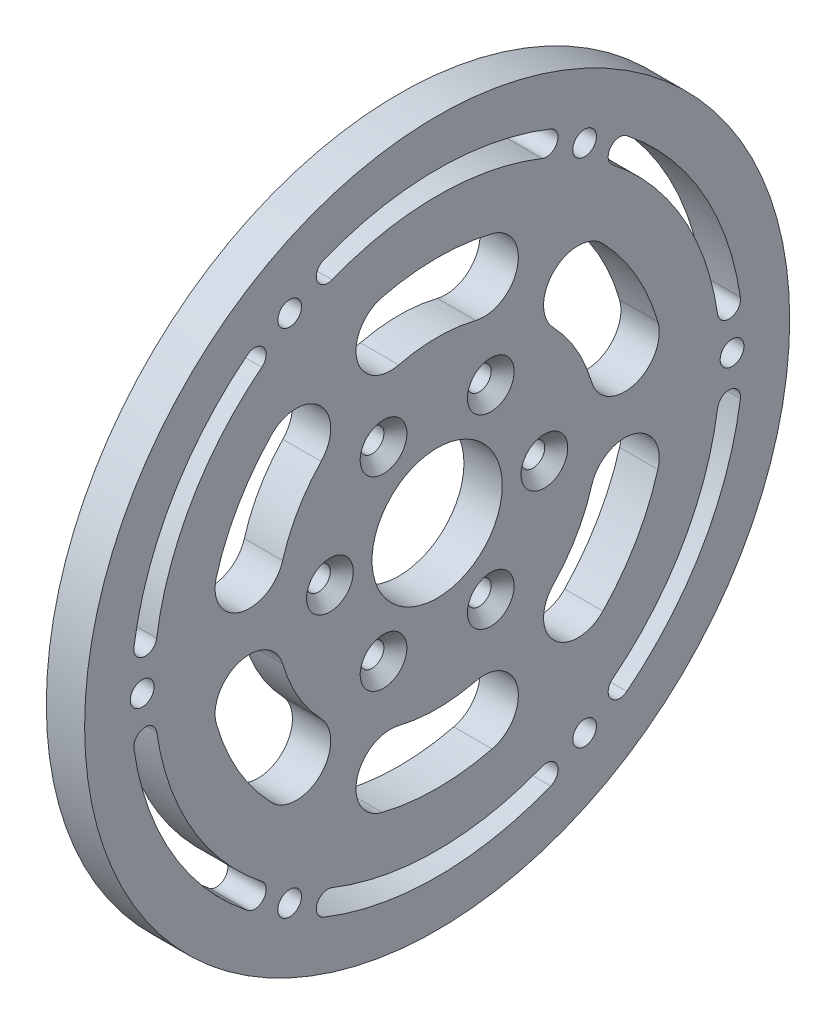
from build123d import *

# Parameters (mm, degrees)
SKETCH_1_W                  = 5
SKETCH_1_H                  = 46.025
CUT_EXTRUDE_1_DEPTH         = 6
CUT_EXTRUDE_2_DEPTH         = 6
CUT_EXTRUDE_3_DEPTH         = 6
CUT_EXTRUDE_4_DEPTH         = 6
CUT_EXTRUDE_5_DEPTH         = 6
CUT_EXTRUDE_6_DEPTH         = 6
CUT_EXTRUDE_7_DEPTH         = 6
CUT_EXTRUDE_8_DEPTH         = 6
CUT_EXTRUDE_9_DEPTH         = 6
CUT_EXTRUDE_10_DEPTH        = 6
CUT_EXTRUDE_11_DEPTH        = 6
CUT_EXTRUDE_12_DEPTH        = 6
HOLE_WIZARD_17_0_17_1_D     = 17
HOLE_WIZARD_17_0_17_1_DEPTH = 5
HOLE_WIZARD_3_0_3_1_D       = 3.1
HOLE_WIZARD_3_0_3_1_DEPTH   = 5
CHAMFER_1_SIZE              = 1.5


with BuildPart() as part:
    # 草图1 → 旋转1 (revolve)
    with BuildSketch(Plane.XY):
        with Locations((0, 23.0125)):
            Rectangle(SKETCH_1_W, SKETCH_1_H)
    revolve(axis=Axis((-2.5, 0, 0), (1, 0, 0)))

    # 草图2 → 切除-拉伸1 (cut, through all)
    with BuildSketch(Plane(origin=(2.5, 0, 0), x_dir=(0, 0, -1), z_dir=(1, 0, 0))):
        with BuildLine():
            ThreePointArc((20.169819251, -5.846228817), (18.186533479, -10.5), (15.147892297, -14.544461453))
            ThreePointArc((15.147892297, -14.544461453), (15.277198907, -20.907108685), (21.639846139, -20.777802075))
            ThreePointArc((21.639846139, -20.777802075), (25.980762114, -15), (28.814027502, -8.351755453))
            ThreePointArc((28.814027502, -8.351755453), (25.744686694, -2.776888009), (20.169819251, -5.846228817))
        make_face()
    extrude(amount=-CUT_EXTRUDE_1_DEPTH, mode=Mode.SUBTRACT)

    # 草图3 → 切除-拉伸2 (cut, through all)
    with BuildSketch(Plane(origin=(2.5, 0, 0), x_dir=(0, 0, -1), z_dir=(1, 0, 0))):
        with BuildLine():
            ThreePointArc((5.021926954, -20.39069027), (0, -21), (-5.021926954, -20.39069027))
            ThreePointArc((-5.021926954, -20.39069027), (-10.467487787, -23.683996694), (-7.174181363, -29.129557528))
            ThreePointArc((-7.174181363, -29.129557528), (0, -30), (7.174181363, -29.129557528))
            ThreePointArc((7.174181363, -29.129557528), (10.467487787, -23.683996694), (5.021926954, -20.39069027))
        make_face()
    extrude(amount=-CUT_EXTRUDE_2_DEPTH, mode=Mode.SUBTRACT)

    # 草图4 → 切除-拉伸3 (cut, through all)
    with BuildSketch(Plane(origin=(2.5, 0, 0), x_dir=(0, 0, -1), z_dir=(1, 0, 0))):
        with BuildLine():
            ThreePointArc((-15.147892297, -14.544461453), (-18.186533479, -10.5), (-20.169819251, -5.846228817))
            ThreePointArc((-20.169819251, -5.846228817), (-25.744686694, -2.776888009), (-28.814027502, -8.351755453))
            ThreePointArc((-28.814027502, -8.351755453), (-25.980762114, -15), (-21.639846139, -20.777802075))
            ThreePointArc((-21.639846139, -20.777802075), (-15.277198907, -20.907108685), (-15.147892297, -14.544461453))
        make_face()
    extrude(amount=-CUT_EXTRUDE_3_DEPTH, mode=Mode.SUBTRACT)

    # 草图5 → 切除-拉伸4 (cut, through all)
    with BuildSketch(Plane(origin=(2.5, 0, 0), x_dir=(0, 0, -1), z_dir=(1, 0, 0))):
        with BuildLine():
            ThreePointArc((15.147892297, 14.544461453), (18.186533479, 10.5), (20.169819251, 5.846228817))
            ThreePointArc((20.169819251, 5.846228817), (25.744686694, 2.776888009), (28.814027502, 8.351755453))
            ThreePointArc((28.814027502, 8.351755453), (25.980762114, 15), (21.639846139, 20.777802075))
            ThreePointArc((21.639846139, 20.777802075), (15.277198907, 20.907108685), (15.147892297, 14.544461453))
        make_face()
    extrude(amount=-CUT_EXTRUDE_4_DEPTH, mode=Mode.SUBTRACT)

    # 草图6 → 切除-拉伸5 (cut, through all)
    with BuildSketch(Plane(origin=(2.5, 0, 0), x_dir=(0, 0, -1), z_dir=(1, 0, 0))):
        with BuildLine():
            ThreePointArc((-20.169819251, 5.846228817), (-18.186533479, 10.5), (-15.147892297, 14.544461453))
            ThreePointArc((-15.147892297, 14.544461453), (-15.277198907, 20.907108685), (-21.639846139, 20.777802075))
            ThreePointArc((-21.639846139, 20.777802075), (-25.980762114, 15), (-28.814027502, 8.351755453))
            ThreePointArc((-28.814027502, 8.351755453), (-25.744686694, 2.776888009), (-20.169819251, 5.846228817))
        make_face()
    extrude(amount=-CUT_EXTRUDE_5_DEPTH, mode=Mode.SUBTRACT)

    # 草图7 → 切除-拉伸6 (cut, through all)
    with BuildSketch(Plane(origin=(2.5, 0, 0), x_dir=(0, 0, -1), z_dir=(1, 0, 0))):
        with BuildLine():
            ThreePointArc((5.021926954, 20.39069027), (10.467487787, 23.683996694), (7.174181363, 29.129557528))
            ThreePointArc((7.174181363, 29.129557528), (0, 30), (-7.174181363, 29.129557528))
            ThreePointArc((-7.174181363, 29.129557528), (-10.467487787, 23.683996694), (-5.021926954, 20.39069027))
            ThreePointArc((-5.021926954, 20.39069027), (0, 21), (5.021926954, 20.39069027))
        make_face()
    extrude(amount=-CUT_EXTRUDE_6_DEPTH, mode=Mode.SUBTRACT)

    # 草图8 → 切除-拉伸7 (cut, through all)
    with BuildSketch(Plane(origin=(2.5, 0, 0), x_dir=(0, 0, -1), z_dir=(1, 0, 0))):
        with BuildLine():
            ThreePointArc((-22.897786978, 29.063574308), (-22.647822626, 31.170115981), (-24.7543643, 31.420080332))
            ThreePointArc((-24.7543643, 31.420080332), (-34.641016151, 20), (-39.587769907, 5.727868172))
            ThreePointArc((-39.587769907, 5.727868172), (-38.318023592, 4.028531744), (-36.618687164, 5.298278059))
            ThreePointArc((-36.618687164, 5.298278059), (-32.04293994, 18.5), (-22.897786978, 29.063574308))
        make_face()
    extrude(amount=-CUT_EXTRUDE_7_DEPTH, mode=Mode.SUBTRACT)

    # 草图9 → 切除-拉伸8 (cut, through all)
    with BuildSketch(Plane(origin=(2.5, 0, 0), x_dir=(0, 0, -1), z_dir=(1, 0, 0))):
        with BuildLine():
            ThreePointArc((-36.618687164, -5.298278059), (-38.318023592, -4.028531744), (-39.587769907, -5.727868172))
            ThreePointArc((-39.587769907, -5.727868172), (-34.641016151, -20), (-24.7543643, -31.420080332))
            ThreePointArc((-24.7543643, -31.420080332), (-22.647822626, -31.170115981), (-22.897786978, -29.063574308))
            ThreePointArc((-22.897786978, -29.063574308), (-32.04293994, -18.5), (-36.618687164, -5.298278059))
        make_face()
    extrude(amount=-CUT_EXTRUDE_8_DEPTH, mode=Mode.SUBTRACT)

    # 草图10 → 切除-拉伸9 (cut, through all)
    with BuildSketch(Plane(origin=(2.5, 0, 0), x_dir=(0, 0, -1), z_dir=(1, 0, 0))):
        with BuildLine():
            ThreePointArc((-13.720900186, -34.361852367), (-15.670200965, -35.198647725), (-14.833405607, -37.147948505))
            ThreePointArc((-14.833405607, -37.147948505), (0, -40), (14.833405607, -37.147948505))
            ThreePointArc((14.833405607, -37.147948505), (15.670200965, -35.198647725), (13.720900186, -34.361852367))
            ThreePointArc((13.720900186, -34.361852367), (0, -37), (-13.720900186, -34.361852367))
        make_face()
    extrude(amount=-CUT_EXTRUDE_9_DEPTH, mode=Mode.SUBTRACT)

    # 草图11 → 切除-拉伸10 (cut, through all)
    with BuildSketch(Plane(origin=(2.5, 0, 0), x_dir=(0, 0, -1), z_dir=(1, 0, 0))):
        with BuildLine():
            ThreePointArc((13.720900186, 34.361852367), (15.670200965, 35.198647725), (14.833405607, 37.147948505))
            ThreePointArc((14.833405607, 37.147948505), (0, 40), (-14.833405607, 37.147948505))
            ThreePointArc((-14.833405607, 37.147948505), (-15.670200965, 35.198647725), (-13.720900186, 34.361852367))
            ThreePointArc((-13.720900186, 34.361852367), (0, 37), (13.720900186, 34.361852367))
        make_face()
    extrude(amount=-CUT_EXTRUDE_10_DEPTH, mode=Mode.SUBTRACT)

    # 草图12 → 切除-拉伸11 (cut, through all)
    with BuildSketch(Plane(origin=(2.5, 0, 0), x_dir=(0, 0, -1), z_dir=(1, 0, 0))):
        with BuildLine():
            ThreePointArc((22.897786978, -29.063574308), (22.647822626, -31.170115981), (24.7543643, -31.420080332))
            ThreePointArc((24.7543643, -31.420080332), (34.641016151, -20), (39.587769907, -5.727868172))
            ThreePointArc((39.587769907, -5.727868172), (38.318023592, -4.028531744), (36.618687164, -5.298278059))
            ThreePointArc((36.618687164, -5.298278059), (32.04293994, -18.5), (22.897786978, -29.063574308))
        make_face()
    extrude(amount=-CUT_EXTRUDE_11_DEPTH, mode=Mode.SUBTRACT)

    # 草图13 → 切除-拉伸12 (cut, through all)
    with BuildSketch(Plane.ZY.offset(2.5)):
        with BuildLine():
            ThreePointArc((-39.587769907, 5.727868172), (-38.318023592, 4.028531744), (-36.618687164, 5.298278059))
            ThreePointArc((-36.618687164, 5.298278059), (-32.04293994, 18.5), (-22.897786978, 29.063574308))
            ThreePointArc((-22.897786978, 29.063574308), (-22.647822626, 31.170115981), (-24.7543643, 31.420080332))
            ThreePointArc((-24.7543643, 31.420080332), (-34.641016151, 20), (-39.587769907, 5.727868172))
        make_face()
    extrude(amount=-CUT_EXTRUDE_12_DEPTH, mode=Mode.SUBTRACT)

    # Ø17.0 (17) 直径孔1
    with Locations(Plane(origin=(2.5, 0, 0), x_dir=(0, 0, -1), z_dir=(1, 0, 0))):
        with Locations((0, 0)):
            Hole(HOLE_WIZARD_17_0_17_1_D / 2, depth=HOLE_WIZARD_17_0_17_1_DEPTH)

    # Ø3.0 (3) 直径孔1
    with Locations(Plane(origin=(2.5, 0, 0), x_dir=(0, 0, -1), z_dir=(1, 0, 0))):
        with Locations((-14, 0), (-7, 12.124355653), (7, 12.124355653), (14, 0), (7, -12.124355653), (-7, -12.124355653), (19.25, -33.341978046), (19.25, 33.341978046), (-38.5, 0), (38.5, 0), (-19.25, -33.341978046), (-19.25, 33.341978046)):
            Hole(HOLE_WIZARD_3_0_3_1_D / 2, depth=HOLE_WIZARD_3_0_3_1_DEPTH)

    # 倒角1
    chamfer_1_edges = [part.edges().sort_by_distance(p)[0] for p in [
        (2.5, -12.124355653, 5.45),
        (2.5, -12.124355653, -8.55),
        (2.5, 0, -15.55),
        (2.5, 12.124355653, -8.55),
        (2.5, 12.124355653, 5.45),
        (2.5, 0, 12.45),
    ]]
    chamfer(chamfer_1_edges, length=CHAMFER_1_SIZE)


solid = part.part
